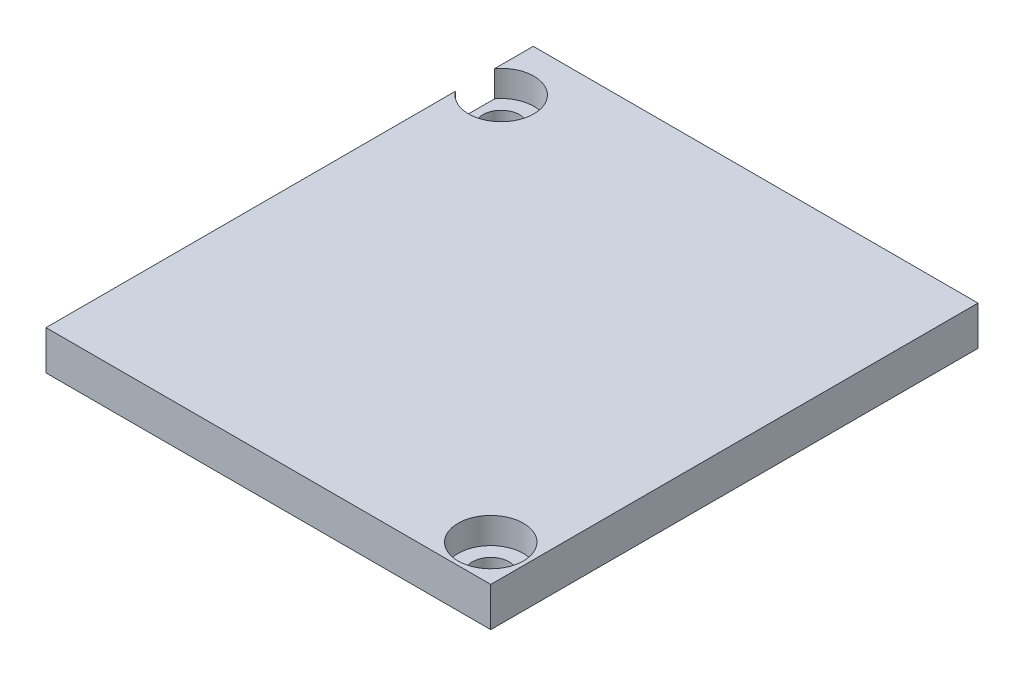
from build123d import *

# Parameters (mm, degrees)
SKETCH1_W           = 34
SKETCH1_H           = 37.25
BOSS_EXTRUDE1_DEPTH = 3
SKETCH2_R           = 2.5
CUT_EXTRUDE1_DEPTH  = 2
SKETCH3_R           = 1.4
CUT_EXTRUDE2_DEPTH  = 2


with BuildPart() as part:
    # Sketch1 → Boss-Extrude1 (new body)
    with BuildSketch(Plane(origin=(0, 0, 0), x_dir=(1, 0, 0), z_dir=(0, 1, 0))):
        Rectangle(SKETCH1_W, SKETCH1_H)
    extrude(amount=BOSS_EXTRUDE1_DEPTH)

    # Sketch2 → Cut-Extrude1 (cut)
    with BuildSketch(Plane(origin=(0, 3, 0), x_dir=(1, 0, 0), z_dir=(0, 1, 0))):
        with Locations((-15, 14.175)):
            Circle(SKETCH2_R)
        with Locations((14.2, -15.825)):
            Circle(SKETCH2_R)
    extrude(amount=-CUT_EXTRUDE1_DEPTH, mode=Mode.SUBTRACT)

    # Sketch3 → Cut-Extrude2 (cut)
    with BuildSketch(Plane(origin=(0, 1, 0), x_dir=(1, 0, 0), z_dir=(0, 1, 0))):
        with Locations((-15, 14.175)):
            Circle(SKETCH3_R)
        with Locations((14.2, -15.825)):
            Circle(SKETCH3_R)
    extrude(amount=-CUT_EXTRUDE2_DEPTH, mode=Mode.SUBTRACT)


solid = part.part
